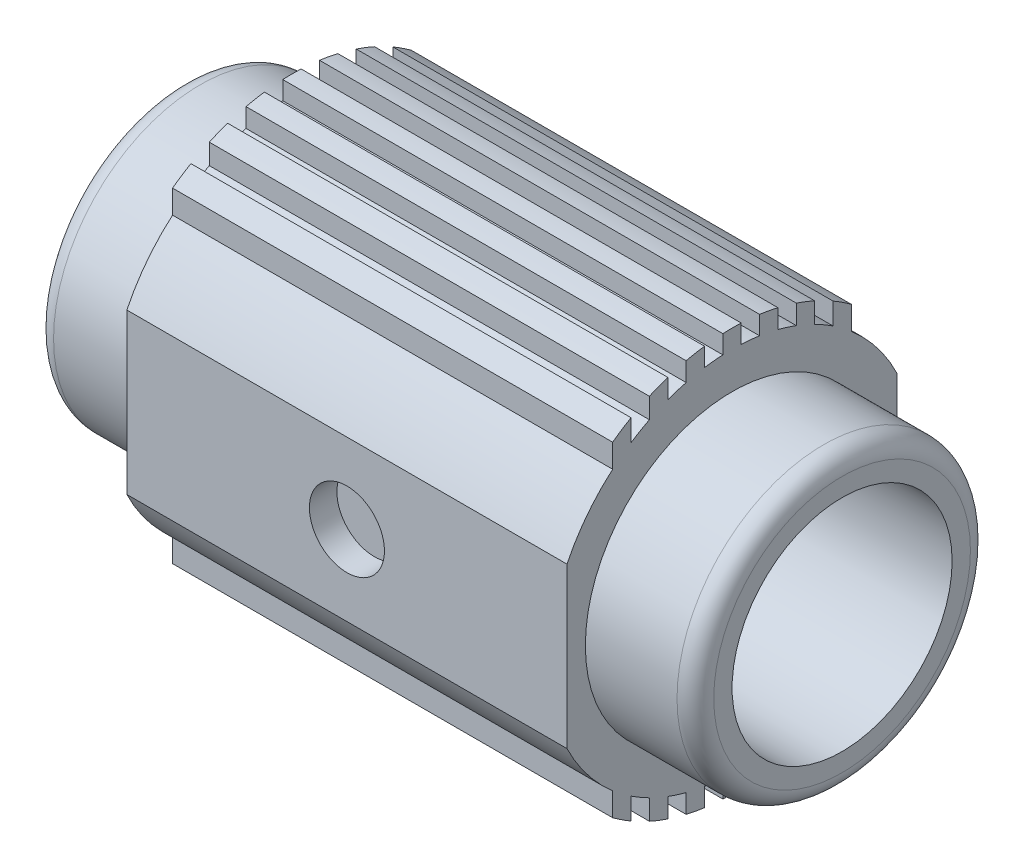
from build123d import *

# Parameters (mm, degrees)
BOSS_EXTRUDE1_DEPTH      = 9.6774
BOSS_EXTRUDE1_DEPTH_BACK = 9.6774
SKETCH2_R                = 6.4516
BOSS_EXTRUDE2_DEPTH      = 4.8387
SKETCH3_R                = 6.4516
BOSS_EXTRUDE3_DEPTH      = 4.8387
SKETCH4_R                = 4.8387
CUT_EXTRUDE1_DEPTH       = 30.0322
FILLET1_R                = 0.80772
SKETCH5_R                = 1.651
CUT_EXTRUDE2_DEPTH       = 1.20904


with BuildPart() as part:
    # Sketch1 → Boss-Extrude1 (new body, two sides)
    with BuildSketch(Plane(origin=(0, 0, 0), x_dir=(0, 0, -1), z_dir=(1, 0, 0))) as boss_extrude1_sk:
        with BuildLine():
            Line((0.40386, 8.863023459), (0.40386, 8.054381252))
            ThreePointArc((0.40386, 8.054381252), (0.80874507, 8.023845192), (1.21158, 7.972968967))
            Line((1.21158, 7.972968967), (1.21158, 8.789104712))
            ThreePointArc((1.21158, 8.789104712), (1.617173927, 8.723590787), (2.0193, 8.639370072))
            Line((2.0193, 8.639370072), (2.0193, 7.807598079))
            ThreePointArc((2.0193, 7.807598079), (2.426507892, 7.690787977), (2.82702, 7.552755667))
            Line((2.82702, 7.552755667), (2.82702, 8.409770844))
            ThreePointArc((2.82702, 8.409770844), (3.234747336, 8.261519073), (3.63474, 8.093513011))
            Line((3.63474, 8.093513011), (3.63474, 7.19894613))
            ThreePointArc((3.63474, 7.19894613), (4.04538399, 6.976462472), (4.44246, 6.730580168))
            Line((4.44246, 6.730580168), (4.44246, 7.679898233))
            ThreePointArc((4.44246, 7.679898233), (4.853501008, 7.426965443), (5.25018, 7.152055487))
            Line((5.25018, 7.152055487), (5.25018, 6.121418971))
            ThreePointArc((5.25018, 6.121418971), (6.389316694, 4.920649595), (7.25932, 3.512610623))
            Line((7.25932, 3.512610623), (7.25932, -3.512610623))
            ThreePointArc((7.25932, -3.512610623), (6.389316694, -4.920649595), (5.25018, -6.121418971))
            Line((5.25018, -6.121418971), (5.25018, -7.152055487))
            ThreePointArc((5.25018, -7.152055487), (4.853501008, -7.426965443), (4.44246, -7.679898233))
            Line((4.44246, -7.679898233), (4.44246, -6.730580168))
            ThreePointArc((4.44246, -6.730580168), (4.04538399, -6.976462472), (3.63474, -7.19894613))
            Line((3.63474, -7.19894613), (3.63474, -8.093513011))
            ThreePointArc((3.63474, -8.093513011), (3.234747336, -8.261519073), (2.82702, -8.409770844))
            Line((2.82702, -8.409770844), (2.82702, -7.552755667))
            ThreePointArc((2.82702, -7.552755667), (2.426507892, -7.690787977), (2.0193, -7.807598079))
            Line((2.0193, -7.807598079), (2.0193, -8.639370072))
            ThreePointArc((2.0193, -8.639370072), (1.617173927, -8.723590787), (1.21158, -8.789104712))
            Line((1.21158, -8.789104712), (1.21158, -7.972968967))
            ThreePointArc((1.21158, -7.972968967), (0.80874507, -8.023845192), (0.40386, -8.054381252))
            Line((0.40386, -8.054381252), (0.40386, -8.863023459))
            ThreePointArc((0.40386, -8.863023459), (0, -8.87222), (-0.40386, -8.863023459))
            Line((-0.40386, -8.863023459), (-0.40386, -8.054381252))
            ThreePointArc((-0.40386, -8.054381252), (-0.80874507, -8.023845192), (-1.21158, -7.972968967))
            Line((-1.21158, -7.972968967), (-1.21158, -8.789104712))
            ThreePointArc((-1.21158, -8.789104712), (-1.617173927, -8.723590787), (-2.0193, -8.639370072))
            Line((-2.0193, -8.639370072), (-2.0193, -7.807598079))
            ThreePointArc((-2.0193, -7.807598079), (-2.426507892, -7.690787977), (-2.82702, -7.552755667))
            Line((-2.82702, -7.552755667), (-2.82702, -8.409770844))
            ThreePointArc((-2.82702, -8.409770844), (-3.234747336, -8.261519073), (-3.63474, -8.093513011))
            Line((-3.63474, -8.093513011), (-3.63474, -7.19894613))
            ThreePointArc((-3.63474, -7.19894613), (-4.04538399, -6.976462472), (-4.44246, -6.730580168))
            Line((-4.44246, -6.730580168), (-4.44246, -7.679898233))
            ThreePointArc((-4.44246, -7.679898233), (-4.853501008, -7.426965443), (-5.25018, -7.152055487))
            Line((-5.25018, -7.152055487), (-5.25018, -6.121418971))
            ThreePointArc((-5.25018, -6.121418971), (-6.389316694, -4.920649595), (-7.25932, -3.512610623))
            Line((-7.25932, -3.512610623), (-7.25932, 3.512610623))
            ThreePointArc((-7.25932, 3.512610623), (-6.389316694, 4.920649595), (-5.25018, 6.121418971))
            Line((-5.25018, 6.121418971), (-5.25018, 7.152055487))
            ThreePointArc((-5.25018, 7.152055487), (-4.853501008, 7.426965443), (-4.44246, 7.679898233))
            Line((-4.44246, 7.679898233), (-4.44246, 6.730580168))
            ThreePointArc((-4.44246, 6.730580168), (-4.04538399, 6.976462472), (-3.63474, 7.19894613))
            Line((-3.63474, 7.19894613), (-3.63474, 8.093513011))
            ThreePointArc((-3.63474, 8.093513011), (-3.234747336, 8.261519073), (-2.82702, 8.409770844))
            Line((-2.82702, 8.409770844), (-2.82702, 7.552755667))
            ThreePointArc((-2.82702, 7.552755667), (-2.426507892, 7.690787977), (-2.0193, 7.807598079))
            Line((-2.0193, 7.807598079), (-2.0193, 8.639370072))
            ThreePointArc((-2.0193, 8.639370072), (-1.617173927, 8.723590787), (-1.21158, 8.789104712))
            Line((-1.21158, 8.789104712), (-1.21158, 7.972968967))
            ThreePointArc((-1.21158, 7.972968967), (-0.80874507, 8.023845192), (-0.40386, 8.054381252))
            Line((-0.40386, 8.054381252), (-0.40386, 8.863023459))
            ThreePointArc((-0.40386, 8.863023459), (0, 8.87222), (0.40386, 8.863023459))
        make_face()
    extrude(amount=BOSS_EXTRUDE1_DEPTH)
    extrude(boss_extrude1_sk.sketch, amount=-BOSS_EXTRUDE1_DEPTH_BACK)

    # Sketch2 → Boss-Extrude2 (add)
    with BuildSketch(Plane(origin=(9.6774, 0, 0), x_dir=(0, 0, -1), z_dir=(1, 0, 0))):
        Circle(SKETCH2_R)
    extrude(amount=BOSS_EXTRUDE2_DEPTH)

    # Sketch3 → Boss-Extrude3 (add)
    with BuildSketch(Plane.ZY.offset(9.6774)):
        Circle(SKETCH3_R)
    extrude(amount=BOSS_EXTRUDE3_DEPTH)

    # Sketch4 → Cut-Extrude1 (cut, through all)
    with BuildSketch(Plane(origin=(14.5161, 0, 0), x_dir=(0, 0, -1), z_dir=(1, 0, 0))):
        Circle(SKETCH4_R)
    extrude(amount=-CUT_EXTRUDE1_DEPTH, mode=Mode.SUBTRACT)

    # Fillet1
    fillet1_edges = [part.edges().sort_by_distance(p)[0] for p in [
        (14.5161, 0, 6.4516),
        (-14.5161, 0, -6.4516),
    ]]
    fillet(fillet1_edges, radius=FILLET1_R)

    # Sketch5 → Cut-Extrude2 (cut)
    with BuildSketch(Plane.XY.offset(7.25932)):
        Circle(SKETCH5_R)
    cut_extrude2 = extrude(amount=-CUT_EXTRUDE2_DEPTH, mode=Mode.SUBTRACT)

    # Mirror1: Cut-Extrude2 across plane
    add(cut_extrude2.mirror(Plane.XY), mode=Mode.SUBTRACT)


solid = part.part
